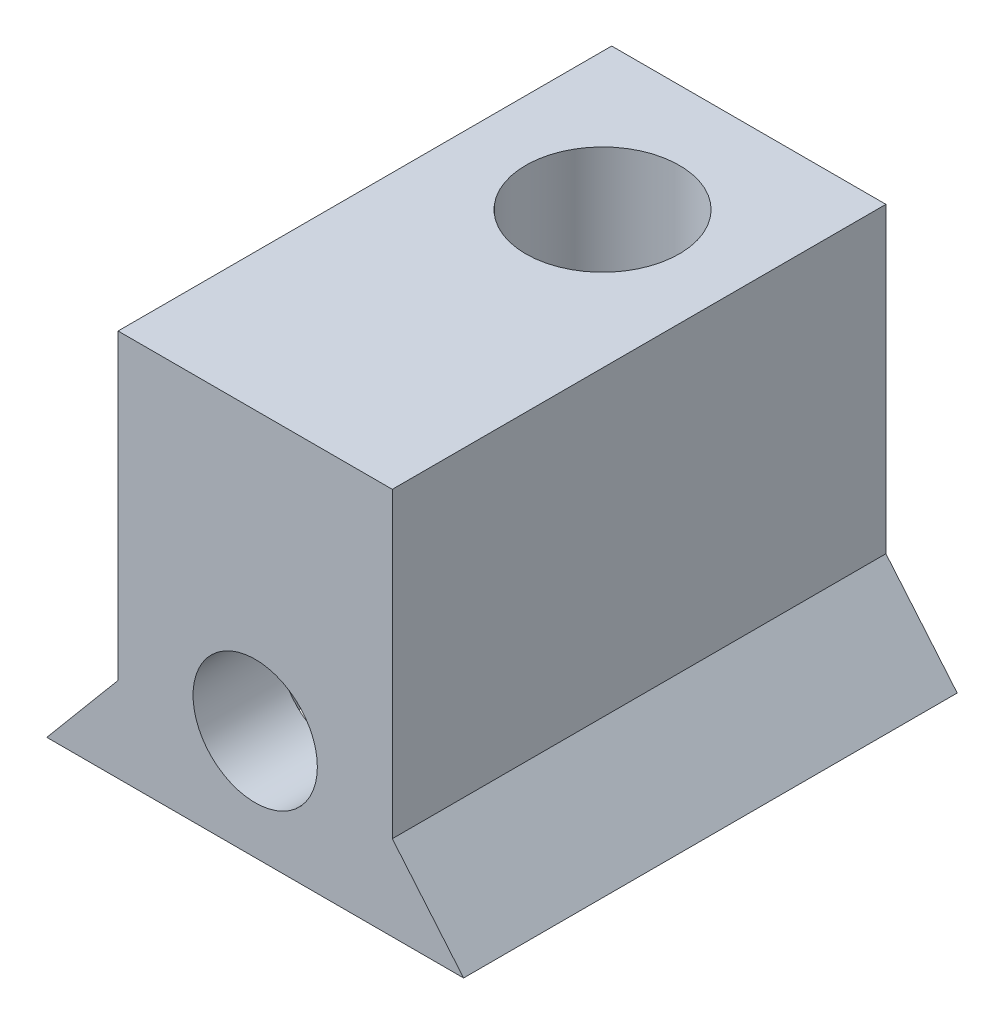
from build123d import *

# Parameters (mm, degrees)
CROQUIS1_R                 = 1.7
SALIENTE_EXTRUIR1_DEPTH    = 13.5
CROQUIS2_R                 = 2.1
CORTAR_EXTRUIR1_DEPTH      = 5.1
CORTAR_EXTRUIR2_DEPTH      = 1.5
CORTAR_EXTRUIR2_DEPTH_BACK = 1.5


with BuildPart() as part:
    # Croquis1 → Saliente-Extruir1 (new body)
    with BuildSketch(Plane.XY):
        Polygon((-5.7, 0), (5.7, 0), (3.75, 2.323919506), (3.75, 10.6), (-3.75, 10.6), (-3.75, 2.323919506), align=None)
        with Locations((0, 3)):
            Circle(CROQUIS1_R, mode=Mode.SUBTRACT)
    extrude(amount=SALIENTE_EXTRUIR1_DEPTH)

    # Croquis2 → Cortar-Extruir1 (cut)
    with BuildSketch(Plane(origin=(0, 10.6, 0), x_dir=(1, 0, 0), z_dir=(0, 1, 0))):
        with Locations((0, -4)):
            Circle(CROQUIS2_R)
    extrude(amount=-CORTAR_EXTRUIR1_DEPTH, mode=Mode.SUBTRACT)

    # Croquis3 → Cortar-Extruir2 (cut, two sides)
    with BuildSketch(Plane.XY.offset(9.65)) as cortar_extruir2_sk:
        Polygon((-2.901185103, 1.325), (-2.901185103, -5.325), (2.901185103, -5.325), (2.901185103, 1.325), (2.901185103, 4.675), (0, 6.35), (-2.901185103, 4.675), align=None)
    extrude(amount=CORTAR_EXTRUIR2_DEPTH, mode=Mode.SUBTRACT)
    extrude(cortar_extruir2_sk.sketch, amount=-CORTAR_EXTRUIR2_DEPTH_BACK, mode=Mode.SUBTRACT)


solid = part.part
